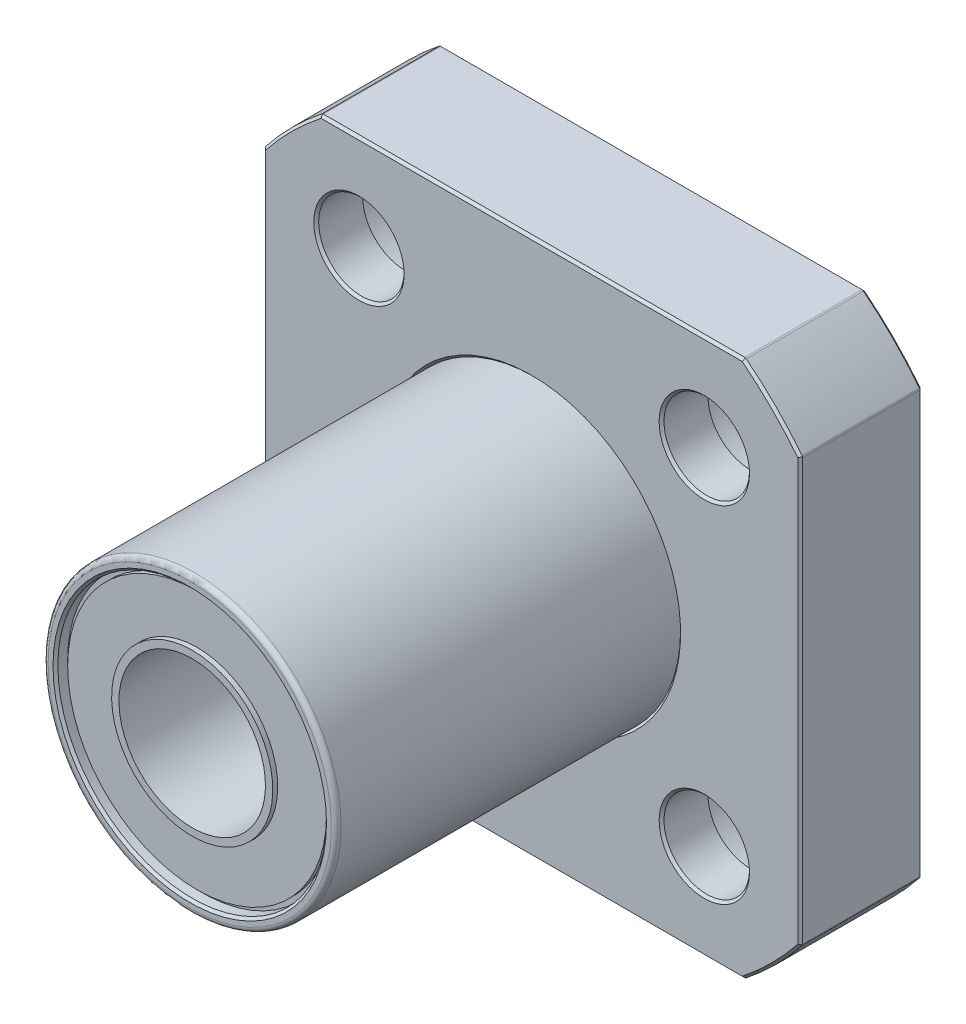
from build123d import *

# Parameters (mm, degrees)
SKETCH_1_W          = 22
SKETCH_1_H          = 22
SKETCH_1_R          = 6
EXTRUDE_1_DEPTH     = 5
SKETCH_3_OUTSIDE_W  = 30.302
SKETCH_3_OUTSIDE_H  = 30.302
SKETCH_3_OUTSIDE_R  = 14
CUT_EXTRUDE_2_DEPTH = 5
SKETCH_5_R          = 1.75
CUT_EXTRUDE_3_DEPTH = 5
SKETCH_5_3_R        = 3
SKETCH_5_3_R_2      = 1.75
CUT_EXTRUDE_4_DEPTH = 3.1
CHAMFER_1_SIZE      = 0.1
SKETCH_7_R          = 6
SKETCH_7_R_2        = 5.5
EXTRUDE_2_DEPTH     = 19
FILLET_1_R          = 0.2
CHAMFER_2_SIZE      = 0.1
FILLET_2_R          = 0.1


with BuildPart() as part:
    # Sketch 1 → Extrude 1 (new body)
    with BuildSketch(Plane.XY):
        Rectangle(SKETCH_1_W, SKETCH_1_H)
        Circle(SKETCH_1_R, mode=Mode.SUBTRACT)
    extrude(amount=EXTRUDE_1_DEPTH)

    # Sketch 3 outside → Cut-Extrude 2 (cut)
    with BuildSketch(Plane.XY.offset(5)):
        Rectangle(SKETCH_3_OUTSIDE_W, SKETCH_3_OUTSIDE_H)
        Circle(SKETCH_3_OUTSIDE_R, mode=Mode.SUBTRACT)
    extrude(amount=-CUT_EXTRUDE_2_DEPTH, mode=Mode.SUBTRACT)

    # Sketch 5 → Cut-Extrude 3 (cut)
    with BuildSketch(Plane.XY):
        with Locations(Location((-7.071067812, 7.071067812, 0), (0, 0, 180))):  # turned: the seam where the file's is
            Circle(SKETCH_5_R)
        with Locations(Location((-7.071067812, -7.071067812, 0), (0, 0, 180))):  # turned: the seam where the file's is
            Circle(SKETCH_5_R)
        with Locations(Location((7.071067812, -7.071067812, 0), (0, 0, 180))):  # turned: the seam where the file's is
            Circle(SKETCH_5_R)
        with Locations(Location((7.071067812, 7.071067812, 0), (0, 0, 180))):  # turned: the seam where the file's is
            Circle(SKETCH_5_R)
    extrude(amount=CUT_EXTRUDE_3_DEPTH, mode=Mode.SUBTRACT)

    # Sketch 5_3 → Cut-Extrude 4 (cut)
    with BuildSketch(Plane.XY):
        with Locations((-7.071067812, 7.071067812)):
            Circle(SKETCH_5_3_R)
        with Locations(Location((-7.071067812, 7.071067812, 0), (0, 0, 180))):  # turned: the seam where the file's is
            Circle(SKETCH_5_3_R_2, mode=Mode.SUBTRACT)
        with Locations(Location((7.071067812, 7.071067812, 0), (0, 0, 180))):  # turned: the seam where the file's is
            Circle(SKETCH_5_3_R)
        with Locations(Location((7.071067812, 7.071067812, 0), (0, 0, 180))):  # turned: the seam where the file's is
            Circle(SKETCH_5_3_R_2, mode=Mode.SUBTRACT)
        with Locations((7.071067812, -7.071067812)):
            Circle(SKETCH_5_3_R)
        with Locations(Location((7.071067812, -7.071067812, 0), (0, 0, 180))):  # turned: the seam where the file's is
            Circle(SKETCH_5_3_R_2, mode=Mode.SUBTRACT)
        with Locations(Location((-7.071067812, -7.071067812, 0), (0, 0, 180))):  # turned: the seam where the file's is
            Circle(SKETCH_5_3_R)
        with Locations(Location((-7.071067812, -7.071067812, 0), (0, 0, 180))):  # turned: the seam where the file's is
            Circle(SKETCH_5_3_R_2, mode=Mode.SUBTRACT)
    extrude(amount=CUT_EXTRUDE_4_DEPTH, mode=Mode.SUBTRACT)

    # Chamfer 1
    chamfer_1_edges = [part.edges().sort_by_distance(p)[0] for p in [
        (10.071067812, 7.071067812, 0),
        (-10.071067812, 7.071067812, 0),
        (-6, 0, 0),
        (-6, 0, 5),
        (0, -11, 0),
        (0, -11, 5),
        (-11, 0, 0),
        (-11, 0, 5),
        (0, 11, 0),
        (0, 11, 5),
        (11, 0, 0),
        (11, 0, 5),
        (9.899494937, -9.899494937, 5),
        (9.899494937, 9.899494937, 5),
        (-9.899494937, 9.899494937, 5),
        (-9.899494937, -9.899494937, 5),
        (9.899494937, 9.899494937, 0),
        (-9.899494937, 9.899494937, 0),
        (9.899494937, -9.899494937, 0),
        (-9.899494937, -9.899494937, 0),
        (8.821067812, 7.071067812, 5),
        (8.821067812, -7.071067812, 5),
        (-5.321067812, -7.071067812, 5),
        (-5.321067812, 7.071067812, 5),
        (-4.071067812, -7.071067812, 0),
        (4.071067812, -7.071067812, 0),
    ]]
    chamfer(chamfer_1_edges, length=CHAMFER_1_SIZE)

    # Sketch 7 → Extrude 2 (add)
    with BuildSketch(Plane(origin=(0, 0, 0), x_dir=(-1, 0, 0), z_dir=(0, 0, -1))):
        Circle(SKETCH_7_R)
        Circle(SKETCH_7_R_2, mode=Mode.SUBTRACT)
    extrude(amount=-EXTRUDE_2_DEPTH)

    # Fillet 1
    fillet_1_edges = [part.edges().sort_by_distance(p)[0] for p in [
        (6, 0, 19),
    ]]
    fillet(fillet_1_edges, radius=FILLET_1_R)

    # Chamfer 2
    chamfer_2_edges = [part.edges().sort_by_distance(p)[0] for p in [
        (5.5, 0, 19),
    ]]
    chamfer(chamfer_2_edges, length=CHAMFER_2_SIZE)

    # Sketch 8 → Revolve 1 (revolve)
    with BuildSketch(Plane(origin=(0, 0, 0), x_dir=(0, 0, -1), z_dir=(1, 0, 0)), mode=Mode.PRIVATE) as revolve_1_sk:
        Polygon((-18.5, 5.5), (-0.4, 5.5), (-0.4, 5.3), (-0.2, 5.3), (-0.2, 3.3), (0, 3.3), (0, 3), (-0.693888948, 3), (-18.206111052, 3), (-18.9, 3), (-18.9, 3.3), (-18.7, 3.3), (-18.7, 5.3), (-18.5, 5.3), align=None)
    revolve(revolve_1_sk.sketch.rotate(Axis((0, 0, 0), (0, 0, 1)), 90), axis=Axis((0, 0, 0), (0, 0, 1)))  # turned: the seam where the file's is

    # Fillet 2
    fillet_2_edges = [part.edges().sort_by_distance(p)[0] for p in [
        (-8.660254038, 11, 2.5),
        (-11, 8.660254038, 2.5),
        (-11, -8.660254038, 2.5),
        (-8.660254038, -11, 2.5),
        (8.660254038, -11, 2.5),
        (11, -8.660254038, 2.5),
        (11, 8.660254038, 2.5),
        (8.660254038, 11, 2.5),
    ]]
    fillet(fillet_2_edges, radius=FILLET_2_R)


solid = part.part
